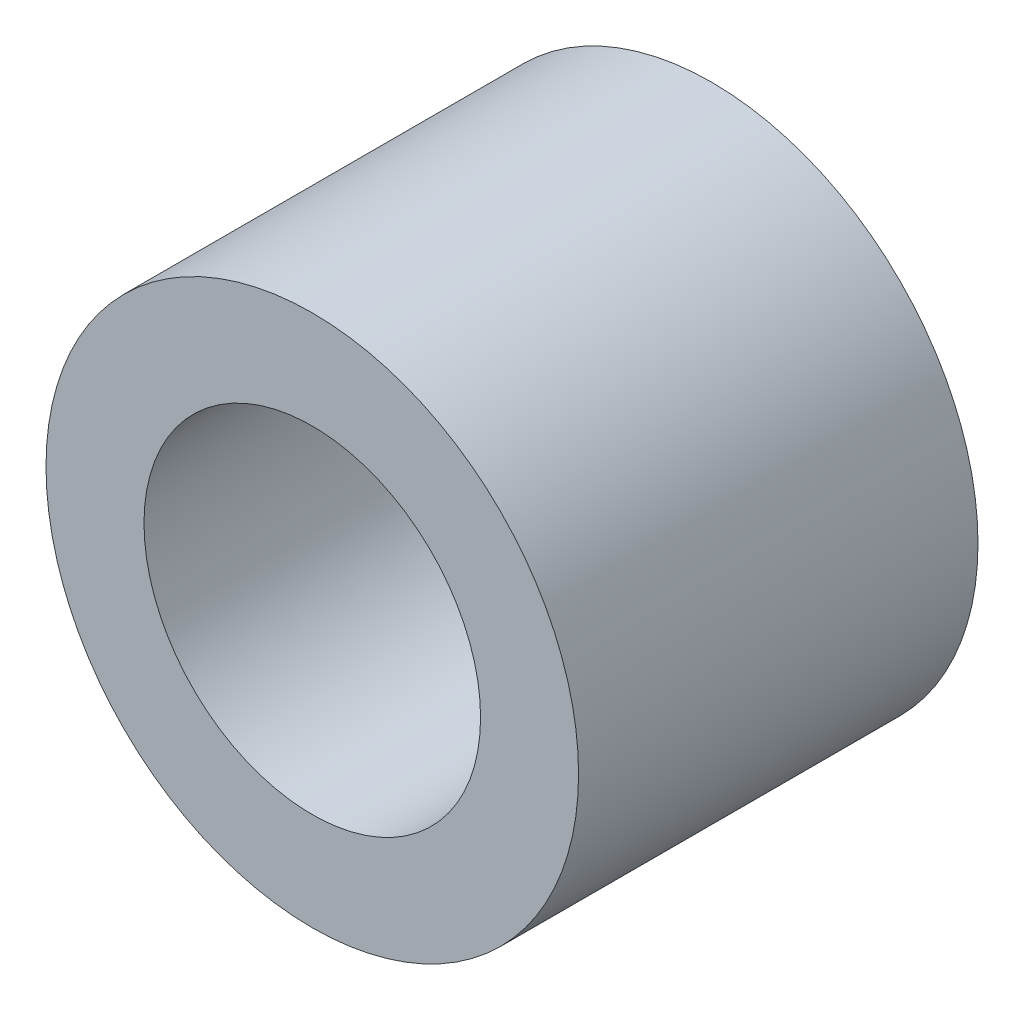
from build123d import *

# Parameters (mm, degrees)
SKETCH1_R      = 6.35
SKETCH1_R_2    = 4.0132
EXTRUDE1_DEPTH = 4.7625


with BuildPart() as part:
    # Sketch1 → Extrude1 (new body, symmetric)
    with BuildSketch(Plane.XY):
        Circle(SKETCH1_R)
        Circle(SKETCH1_R_2, mode=Mode.SUBTRACT)
    extrude(amount=EXTRUDE1_DEPTH, both=True)


solid = part.part
